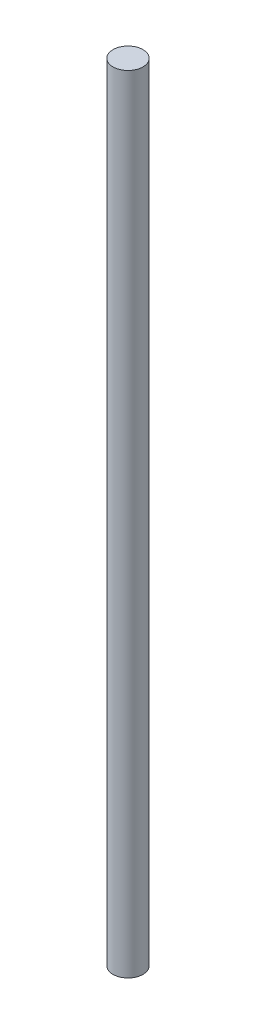
from build123d import *

# Parameters (mm, degrees)
SKETCH1_R           = 5
BOSS_EXTRUDE1_DEPTH = 262


with BuildPart() as part:
    # Sketch1 → Boss-Extrude1 (new body)
    with BuildSketch(Plane(origin=(0, 0, 0), x_dir=(1, 0, 0), z_dir=(0, 1, 0))):
        Circle(SKETCH1_R)
    extrude(amount=BOSS_EXTRUDE1_DEPTH)


solid = part.part
